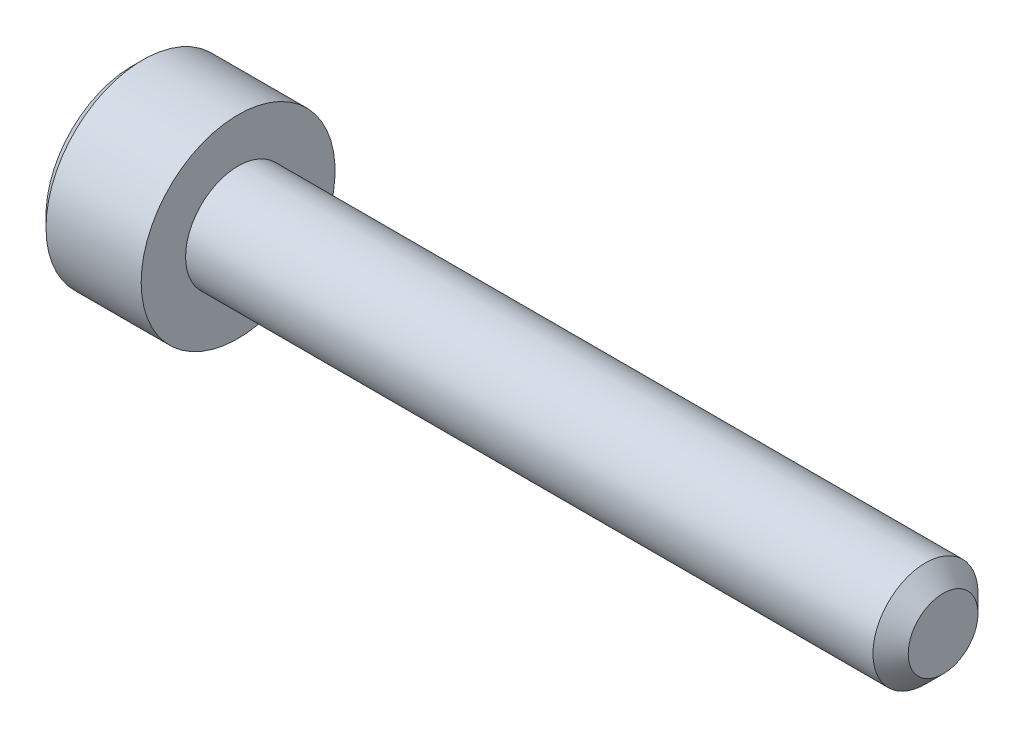
from build123d import *

# Parameters (mm, degrees)
CHAMFER1_SIZE      = 0.5
CHAMFER2_SIZE      = 0.3
CUT_EXTRUDE1_DEPTH = 2.5
CHAMFER3_SIZE      = 0.3


with BuildPart() as part:
    # Sketch1 → Revolve1 (revolve)
    with BuildSketch(Plane.XY):
        Polygon((0, 0), (0, 2.75), (3, 2.75), (3, 1.49), (23, 1.49), (23, 0), align=None)
    revolve(axis=Axis((-88.705490849, 0, 0), (1, 0, 0)))

    # Chamfer1
    chamfer1_edges = [part.edges().sort_by_distance(p)[0] for p in [
        (23, -1.49, 0),
    ]]
    chamfer(chamfer1_edges, length=CHAMFER1_SIZE)

    # Chamfer2
    chamfer2_edges = [part.edges().sort_by_distance(p)[0] for p in [
        (0, -2.75, 0),
    ]]
    chamfer(chamfer2_edges, length=CHAMFER2_SIZE)

    # Sketch3 → Cut-Extrude1 (cut)
    with BuildSketch(Plane(origin=(0, 0, 0), x_dir=(0, 0, -1), z_dir=(1, 0, 0))):
        Polygon((-1.443375673, 0), (-0.721687836, -1.25), (0.721687836, -1.25), (1.443375673, 0), (0.721687836, 1.25), (-0.721687836, 1.25), align=None)
    extrude(amount=CUT_EXTRUDE1_DEPTH, mode=Mode.SUBTRACT)

    # Chamfer3
    chamfer3_edges = [part.edges().sort_by_distance(p)[0] for p in [
        (0, 0.625, 1.082531755),
        (0, -0.625, 1.082531755),
        (0, -1.25, 0),
        (0, -0.625, -1.082531755),
        (0, 0.625, -1.082531755),
        (0, 1.25, 0),
    ]]
    chamfer(chamfer3_edges, length=CHAMFER3_SIZE)


solid = part.part
